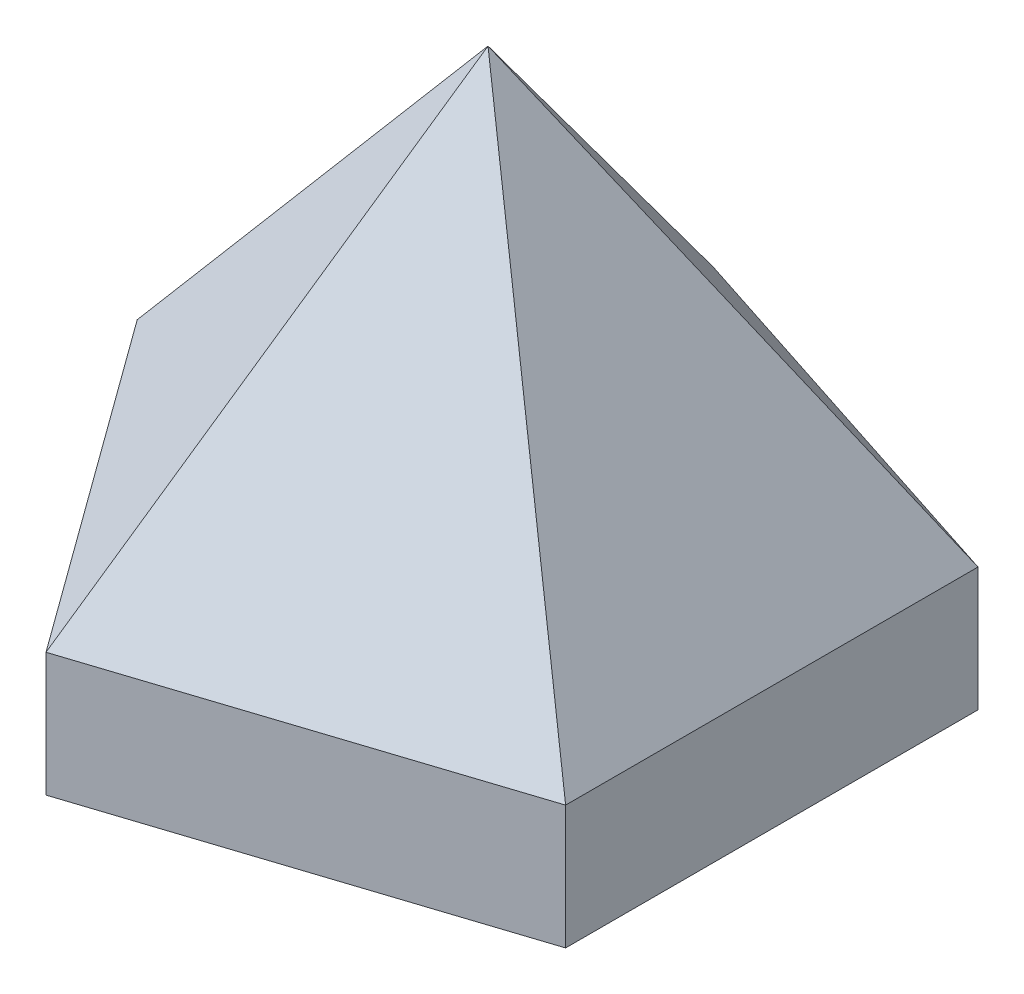
from build123d import *

# Parameters (mm, degrees)
EXTRUDE1_DEPTH = 15


with BuildPart() as part:
    # Sketch1 → Extrude1 (new body)
    with BuildSketch(Plane(origin=(0, 0, 0), x_dir=(1, 0, 0), z_dir=(0, 1, 0))):
        Polygon((69.389262615, -95.450849719), (116.942088429, -80), (116.942088429, -30), (69.389262615, -14.549150281), (40, -55), align=None)
    extrude(amount=EXTRUDE1_DEPTH)

    # Sketch3 → Loft1 section 0
    with BuildSketch(Plane(origin=(0, 15, 0), x_dir=(1, 0, 0), z_dir=(0, 1, 0)), mode=Mode.PRIVATE) as loft1_s0:
        Polygon((69.389262615, -95.450849719), (40, -55), (69.389262615, -14.549150281), (116.942088429, -30), (116.942088429, -80), align=None)
    loft([loft1_s0.sketch, Vertex(82.532540418, 65, 55)])


solid = part.part
